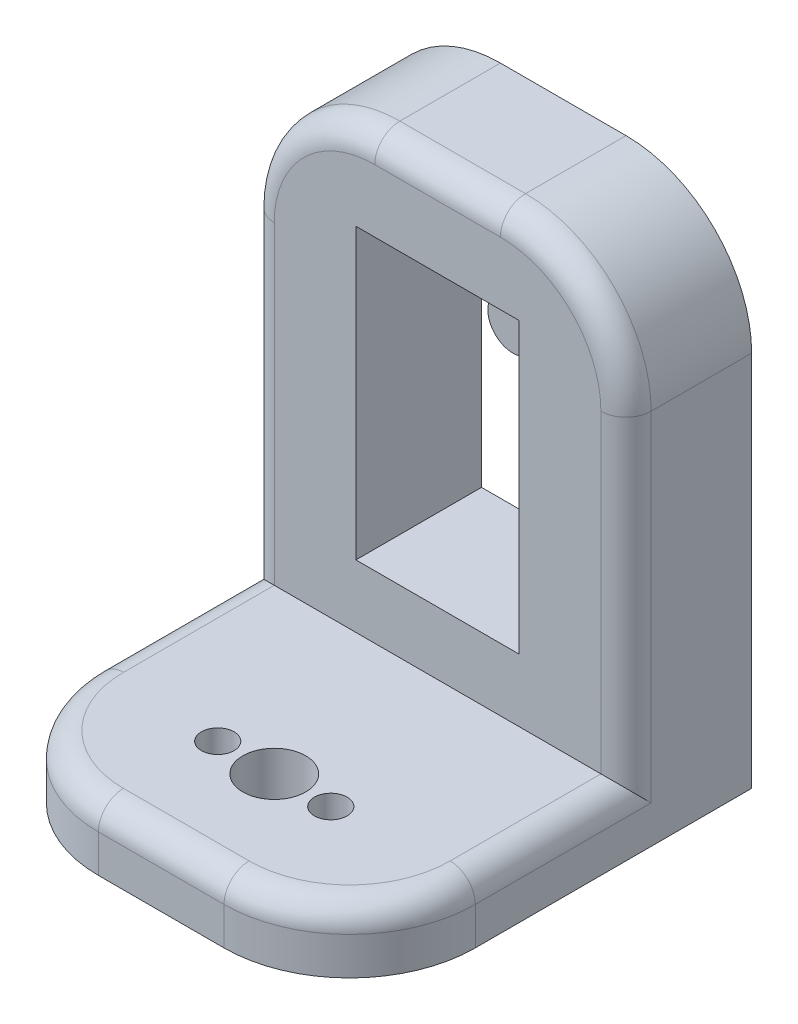
from build123d import *

# Parameters (mm, degrees)
SKETCH1_W           = 30
SKETCH1_H           = 30
SKETCH1_R           = 1.3
SKETCH1_R_2         = 2.5
BOSS_EXTRUDE1_DEPTH = 5
SKETCH2_W           = 10
SKETCH2_H           = 40
BOSS_EXTRUDE2_DEPTH = 30
SKETCH3_W           = 13
SKETCH3_H           = 23
CUT_EXTRUDE1_DEPTH  = 39
SKETCH3_3_R         = 1.05
CUT_EXTRUDE2_DEPTH  = 8
SKETCH3_6_R         = 2
BOSS_EXTRUDE3_DEPTH = 4
SKETCH5_W           = 30
SKETCH5_H           = 6
CUT_EXTRUDE4_DEPTH  = 5
FILLET4_R           = 10
FILLET5_R           = 2


with BuildPart() as part:
    # Sketch1 → Boss-Extrude1 (new body)
    with BuildSketch(Plane(origin=(0, 0, 0), x_dir=(1, 0, 0), z_dir=(0, 1, 0))):
        with Locations((15, 15)):
            Rectangle(SKETCH1_W, SKETCH1_H)
        with Locations((19.5, 15)):
            Circle(SKETCH1_R, mode=Mode.SUBTRACT)
        with Locations((10.5, 15)):
            Circle(SKETCH1_R, mode=Mode.SUBTRACT)
        with Locations((15, 15)):
            Circle(SKETCH1_R_2, mode=Mode.SUBTRACT)
    extrude(amount=BOSS_EXTRUDE1_DEPTH)

    # Sketch2 → Boss-Extrude2 (add)
    with BuildSketch(Plane(origin=(30, 0, 0), x_dir=(0, 0, -1), z_dir=(1, 0, 0))):
        with Locations((33, 20)):
            Rectangle(SKETCH2_W, SKETCH2_H)
    extrude(amount=-BOSS_EXTRUDE2_DEPTH)

    # Sketch3 → Cut-Extrude1 (cut, through all)
    with BuildSketch(Plane(origin=(0, 0, -38), x_dir=(-1, 0, 0), z_dir=(0, 0, -1))):
        with Locations((-15, 21.5)):
            Rectangle(SKETCH3_W, SKETCH3_H)
    extrude(amount=-CUT_EXTRUDE1_DEPTH, mode=Mode.SUBTRACT)

    # Sketch3_3 → Cut-Extrude2 (cut)
    with BuildSketch(Plane(origin=(0, 0, -38), x_dir=(-1, 0, 0), z_dir=(0, 0, -1))):
        with Locations((-15, 35.5)):
            Circle(SKETCH3_3_R)
        with Locations((-15, 7.5)):
            Circle(SKETCH3_3_R)
    extrude(amount=-CUT_EXTRUDE2_DEPTH, mode=Mode.SUBTRACT)

    # Sketch5 → Cut-Extrude4 (cut)
    with BuildSketch(Plane(origin=(0, 5, 0), x_dir=(1, 0, 0), z_dir=(0, 1, 0))):
        with Locations((15, 3)):
            Rectangle(SKETCH5_W, SKETCH5_H)
    extrude(amount=-CUT_EXTRUDE4_DEPTH, mode=Mode.SUBTRACT)

    # Fillet4
    fillet4_edges = [part.edges().sort_by_distance(p)[0] for p in [
        (30, 40, -33),
        (0, 40, -33),
        (0, 2.5, -6),
        (30, 2.5, -6),
    ]]
    fillet(fillet4_edges, radius=FILLET4_R)

    # Fillet5
    fillet5_edges = [part.edges().sort_by_distance(p)[0] for p in [
        (2.928932188, 5, -8.928932188),
        (15, 40, -28),
        (0, 17.5, -28),
        (30, 17.5, -28),
        (27.071067812, 37.071067812, -28),
        (2.928932188, 37.071067812, -28),
        (0, 5, -22),
        (30, 5, -22),
        (15, 5, -6),
        (27.071067812, 5, -8.928932188),
    ]]
    fillet(fillet5_edges, radius=FILLET5_R)


with BuildPart() as body_2:
    # Sketch3_6 → Boss-Extrude3 (new body)
    with BuildSketch(Plane(origin=(0, 0, -38), x_dir=(-1, 0, 0), z_dir=(0, 0, -1))):
        with Locations((-15, 26.5)):
            Circle(SKETCH3_6_R)
    extrude(amount=-BOSS_EXTRUDE3_DEPTH)


solid = Compound([part.part, body_2.part])
